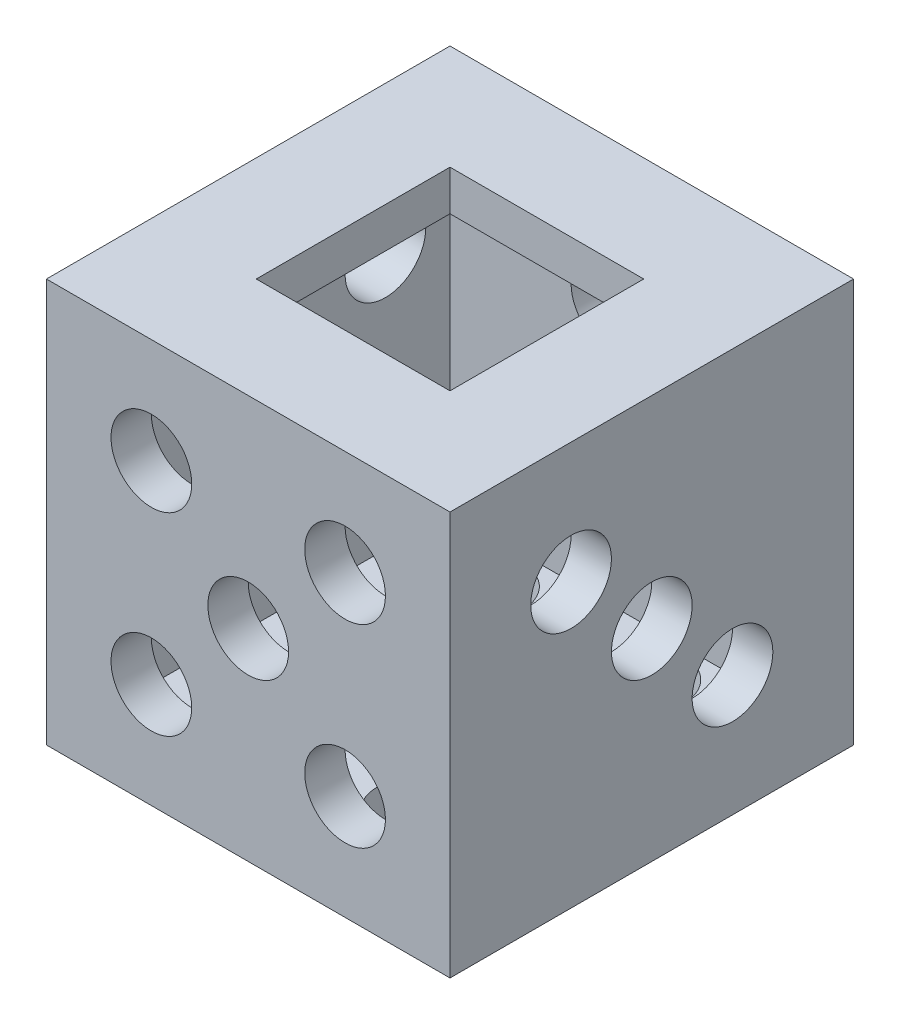
from build123d import *

# Parameters (mm, degrees)
SKETCH1_W           = 25
SKETCH1_H           = 25
BOSS_EXTRUDE1_DEPTH = 25
SHELL1_T            = 2.5
SKETCH2_W           = 12
SKETCH2_H           = 12
CUT_EXTRUDE1_DEPTH  = 15
SKETCH3_R           = 2.5
CUT_EXTRUDE2_DEPTH  = 15
SKETCH4_R           = 2.5
CUT_EXTRUDE6_DEPTH  = 15
SKETCH4_3_R         = 2.5
CUT_EXTRUDE7_DEPTH  = 15
SKETCH5_R           = 2.5
CUT_EXTRUDE8_DEPTH  = 15
SKETCH5_4_R         = 2.5
CUT_EXTRUDE9_DEPTH  = 15
SKETCH5_5_R         = 2.5
CUT_EXTRUDE10_DEPTH = 15
SKETCH7_R           = 2.5
CUT_EXTRUDE11_DEPTH = 15
SKETCH8_R           = 2.5
CUT_EXTRUDE12_DEPTH = 10


with BuildPart() as part:
    # Sketch1 → Boss-Extrude1 (new body)
    with BuildSketch(Plane(origin=(0, 0, 0), x_dir=(1, 0, 0), z_dir=(0, 1, 0))):
        Rectangle(SKETCH1_W, SKETCH1_H)
    extrude(amount=BOSS_EXTRUDE1_DEPTH)

    # Shell1 (no face opened: a closed hollow body)
    add(offset(amount=-SHELL1_T, mode=Mode.PRIVATE), mode=Mode.SUBTRACT)

    # Sketch2 → Cut-Extrude1 (cut)
    with BuildSketch(Plane(origin=(0, 25, 0), x_dir=(1, 0, 0), z_dir=(0, 1, 0))):
        Rectangle(SKETCH2_W, SKETCH2_H)
    extrude(amount=-CUT_EXTRUDE1_DEPTH, mode=Mode.SUBTRACT)

    # Sketch3 → Cut-Extrude2 (cut)
    with BuildSketch(Plane.XZ):
        with Locations((-5, 7)):
            Circle(SKETCH3_R)
        with Locations((-5, 0)):
            Circle(SKETCH3_R)
        with Locations((-5, -7)):
            Circle(SKETCH3_R)
        with Locations((5, 7)):
            Circle(SKETCH3_R)
        with Locations((5, 0)):
            Circle(SKETCH3_R)
        with Locations((5, -7)):
            Circle(SKETCH3_R)
    extrude(amount=-CUT_EXTRUDE2_DEPTH, mode=Mode.SUBTRACT)

    # Sketch4 → Cut-Extrude6 (cut)
    with BuildSketch(Plane(origin=(12.5, 0, 0), x_dir=(0, 0, -1), z_dir=(1, 0, 0))):
        with Locations((-5, 17.5)):
            Circle(SKETCH4_R)
    extrude(amount=-CUT_EXTRUDE6_DEPTH, mode=Mode.SUBTRACT)

    # Sketch4_3 → Cut-Extrude7 (cut)
    with BuildSketch(Plane(origin=(12.5, 0, 0), x_dir=(0, 0, -1), z_dir=(1, 0, 0))):
        with Locations((0, 12.5)):
            Circle(SKETCH4_3_R)
        with Locations((5, 7.5)):
            Circle(SKETCH4_3_R)
    extrude(amount=-CUT_EXTRUDE7_DEPTH, mode=Mode.SUBTRACT)

    # Sketch5 → Cut-Extrude8 (cut)
    with BuildSketch(Plane.ZY.offset(12.5)):
        with Locations((-6, 18.5)):
            Circle(SKETCH5_R)
    extrude(amount=-CUT_EXTRUDE8_DEPTH, mode=Mode.SUBTRACT)

    # Sketch5_4 → Cut-Extrude9 (cut)
    with BuildSketch(Plane.ZY.offset(12.5)):
        with Locations((6, 18.5)):
            Circle(SKETCH5_4_R)
    extrude(amount=-CUT_EXTRUDE9_DEPTH, mode=Mode.SUBTRACT)

    # Sketch5_5 → Cut-Extrude10 (cut)
    with BuildSketch(Plane.ZY.offset(12.5)):
        with Locations((6, 6.5)):
            Circle(SKETCH5_5_R)
        with Locations((-6, 6.5)):
            Circle(SKETCH5_5_R)
    extrude(amount=-CUT_EXTRUDE10_DEPTH, mode=Mode.SUBTRACT)

    # Sketch7 → Cut-Extrude11 (cut)
    with BuildSketch(Plane.XY.offset(12.5)):
        with Locations((-6, 18.5)):
            Circle(SKETCH7_R)
        with Locations((0, 12.5)):
            Circle(SKETCH7_R)
        with Locations((6, 18.5)):
            Circle(SKETCH7_R)
        with Locations((6, 6.5)):
            Circle(SKETCH7_R)
        with Locations((-6, 6.5)):
            Circle(SKETCH7_R)
    extrude(amount=-CUT_EXTRUDE11_DEPTH, mode=Mode.SUBTRACT)

    # Sketch8 → Cut-Extrude12 (cut)
    with BuildSketch(Plane(origin=(0, 0, -12.5), x_dir=(-1, 0, 0), z_dir=(0, 0, -1))):
        with Locations((0, 18.5)):
            Circle(SKETCH8_R)
        with Locations((0, 6.5)):
            Circle(SKETCH8_R)
    extrude(amount=-CUT_EXTRUDE12_DEPTH, mode=Mode.SUBTRACT)


solid = part.part
